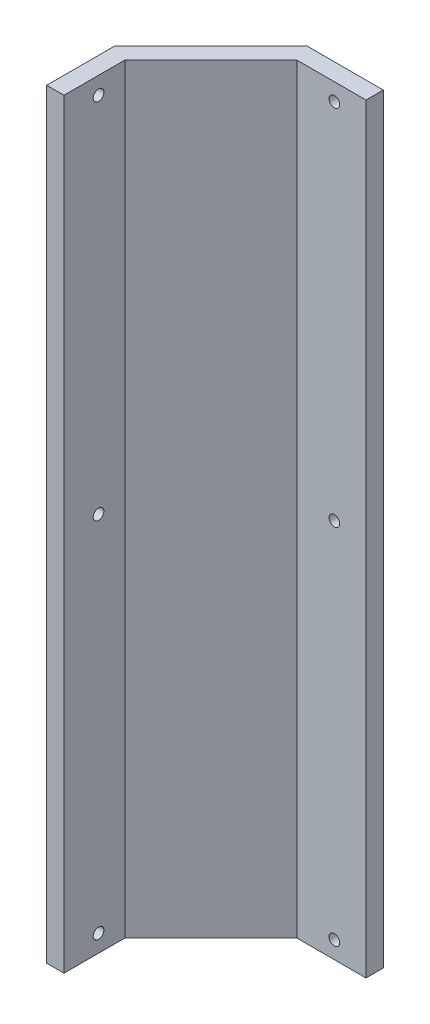
from build123d import *

# Parameters (mm, degrees)
EXTRUDE_1_DEPTH          = 220
SKETCH_3_R               = 1.55
CUT_EXTRUDE_1_DEPTH      = 10
CUT_EXTRUDE_2_DEPTH      = 120
CUT_EXTRUDE_2_DEPTH_BACK = 10
SKETCH_4_R               = 1.55


with BuildPart() as part:
    # 草图2 → 凸台-拉伸1 (new body)
    with BuildSketch(Plane(origin=(0, 0, 0), x_dir=(1, 0, 0), z_dir=(0, 1, 0))):
        Polygon((-87.523326774, 42.5), (-112.419250373, 17.604076401), (-112.419250373, 0), (-117.419250373, 0), (-117.419250373, 19.675144213), (-89.594394586, 47.5), (-67.523326774, 47.5), (-67.523326774, 42.5), align=None)
    extrude(amount=EXTRUDE_1_DEPTH)

    # 草图3 → 切除-拉伸1 (cut)
    with BuildSketch(Plane.ZY.offset(117.419250373)):
        with Locations((-10, 110)):
            Circle(SKETCH_3_R)
        with Locations((-10, 5)):
            Circle(SKETCH_3_R)
        with Locations((-10, 215)):
            Circle(SKETCH_3_R)
    extrude(amount=-CUT_EXTRUDE_1_DEPTH, mode=Mode.SUBTRACT)

    # 草图4 → 切除-拉伸2 (cut, two sides: drawn at the far end of the back side and taken through both)
    with BuildSketch(Plane.XY.offset(-42.5).offset(-CUT_EXTRUDE_2_DEPTH_BACK)):
        with Locations((-76.693326774, 110)):
            Circle(SKETCH_4_R)
        with Locations((-76.693326774, 5)):
            Circle(SKETCH_4_R)
        with Locations((-76.693326774, 215)):
            Circle(SKETCH_4_R)
    extrude(amount=CUT_EXTRUDE_2_DEPTH + CUT_EXTRUDE_2_DEPTH_BACK, mode=Mode.SUBTRACT)


solid = part.part
